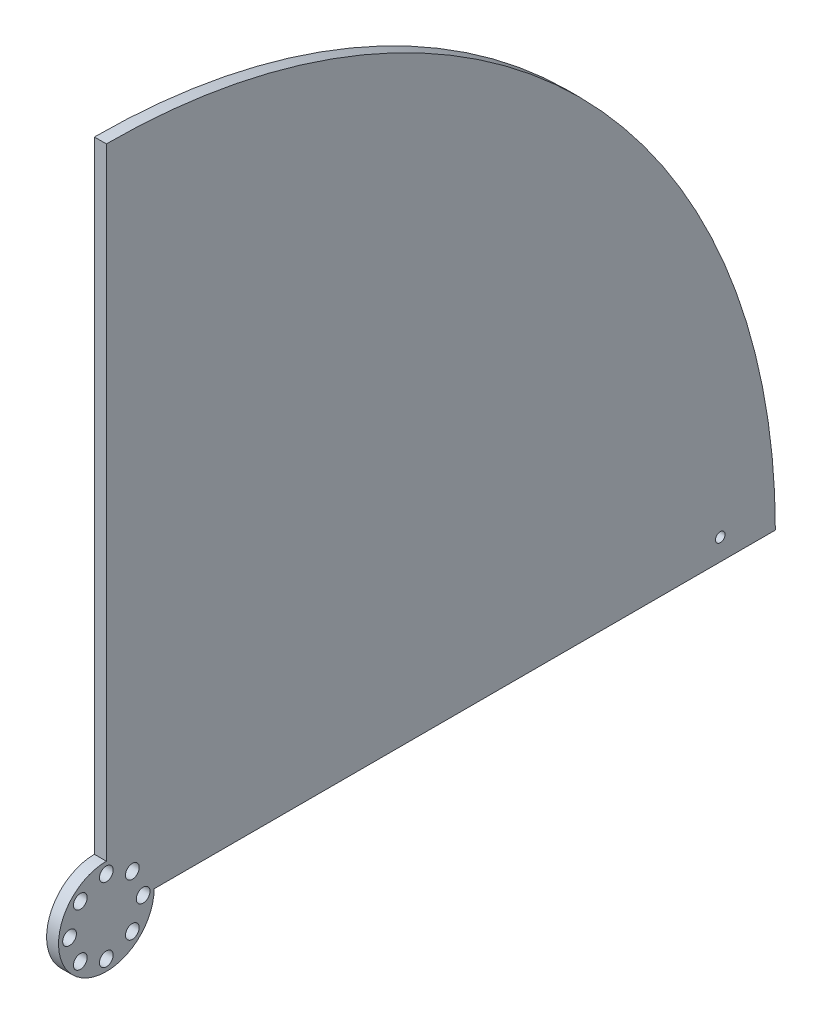
from build123d import *

# Parameters (mm, degrees)
BOSS_EXTRUDE1_DEPTH = 3.175
BOSS_EXTRUDE2_DEPTH = 3.175
SKETCH3_R           = 1.8288
CUT_EXTRUDE1_DEPTH  = 4.175
SKETCH5_R           = 1.27
CUT_EXTRUDE2_DEPTH  = 4.175


with BuildPart() as part:
    # Sketch1 → Boss-Extrude1 (new body)
    with BuildSketch(Plane(origin=(0, 0, 0), x_dir=(0, 0, -1), z_dir=(1, 0, 0))):
        with BuildLine():
            Line((0, 177.8), (0, 0))
            Line((0, 0), (177.8, 0))
            ThreePointArc((177.8, 0), (125.723585695, 125.723585695), (0, 177.8))
        make_face()
    extrude(amount=BOSS_EXTRUDE1_DEPTH)

    # Sketch2 → Boss-Extrude2 (add)
    with BuildSketch(Plane(origin=(3.175, 0, 0), x_dir=(0, 0, -1), z_dir=(1, 0, 0))):
        with BuildLine():
            Line((0, 0), (0, 12.7))
            ThreePointArc((0, 12.7), (-8.980256121, -8.980256121), (12.7, 0))
            Line((12.7, 0), (0, 0))
        make_face()
    extrude(amount=-BOSS_EXTRUDE2_DEPTH)

    # Sketch3 → Cut-Extrude1 (cut, through all)
    with BuildSketch(Plane(origin=(3.175, 0, 0), x_dir=(0, 0, -1), z_dir=(1, 0, 0))):
        with Locations((0, 9.779)):
            Circle(SKETCH3_R)
        with Locations((6.914797213, 6.914797213)):
            Circle(SKETCH3_R)
        with Locations((9.779, 0)):
            Circle(SKETCH3_R)
        with Locations((6.914797213, -6.914797213)):
            Circle(SKETCH3_R)
        with Locations((0, -9.779)):
            Circle(SKETCH3_R)
        with Locations((-6.914797213, -6.914797213)):
            Circle(SKETCH3_R)
        with Locations((-9.779, 0)):
            Circle(SKETCH3_R)
        with Locations((-6.914797213, 6.914797213)):
            Circle(SKETCH3_R)
    extrude(amount=-CUT_EXTRUDE1_DEPTH, mode=Mode.SUBTRACT)

    # Sketch5 → Cut-Extrude2 (cut, through all)
    with BuildSketch(Plane(origin=(3.175, 0, 0), x_dir=(0, 0, -1), z_dir=(1, 0, 0))):
        with Locations((163.159047333, 5.697639482)):
            Circle(SKETCH5_R)
    extrude(amount=-CUT_EXTRUDE2_DEPTH, mode=Mode.SUBTRACT)


solid = part.part
